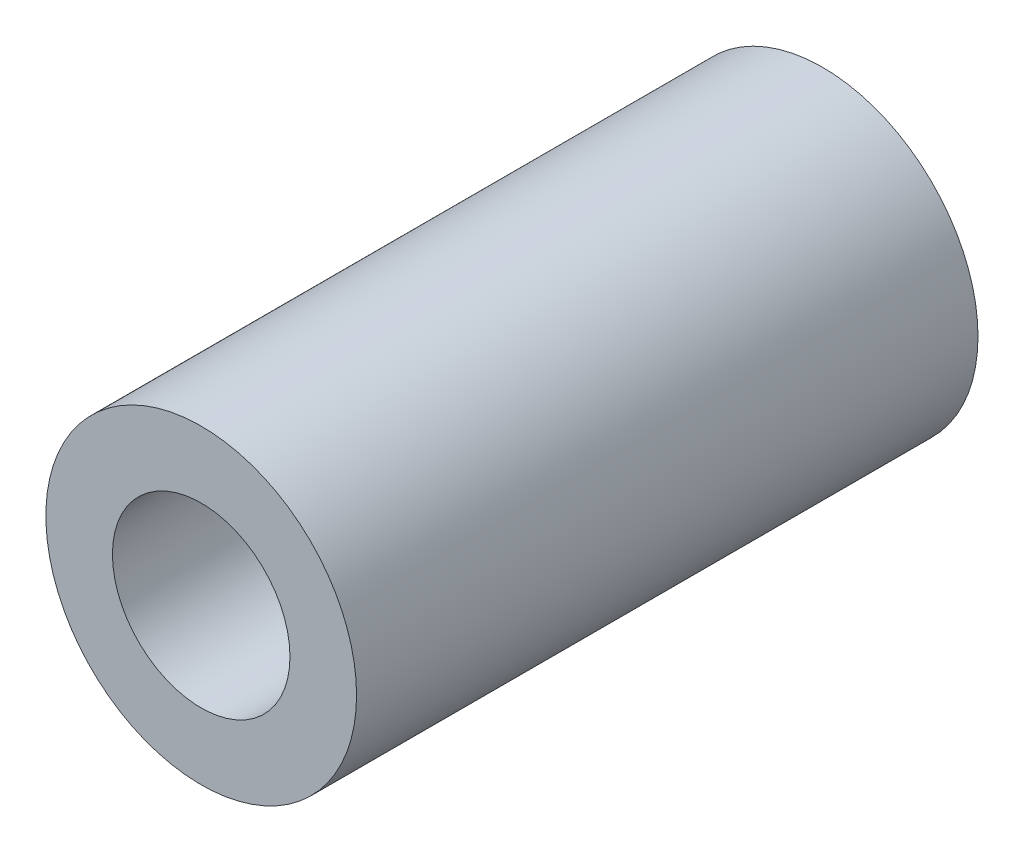
from build123d import *

# Parameters (mm, degrees)
SKETCH1_R           = 7
SKETCH1_R_2         = 4
BOSS_EXTRUDE1_DEPTH = 14


with BuildPart() as part:
    # Sketch1 → Boss-Extrude1 (new body, symmetric)
    with BuildSketch(Plane.XY):
        Circle(SKETCH1_R)
        Circle(SKETCH1_R_2, mode=Mode.SUBTRACT)
    extrude(amount=BOSS_EXTRUDE1_DEPTH, both=True)


solid = part.part
